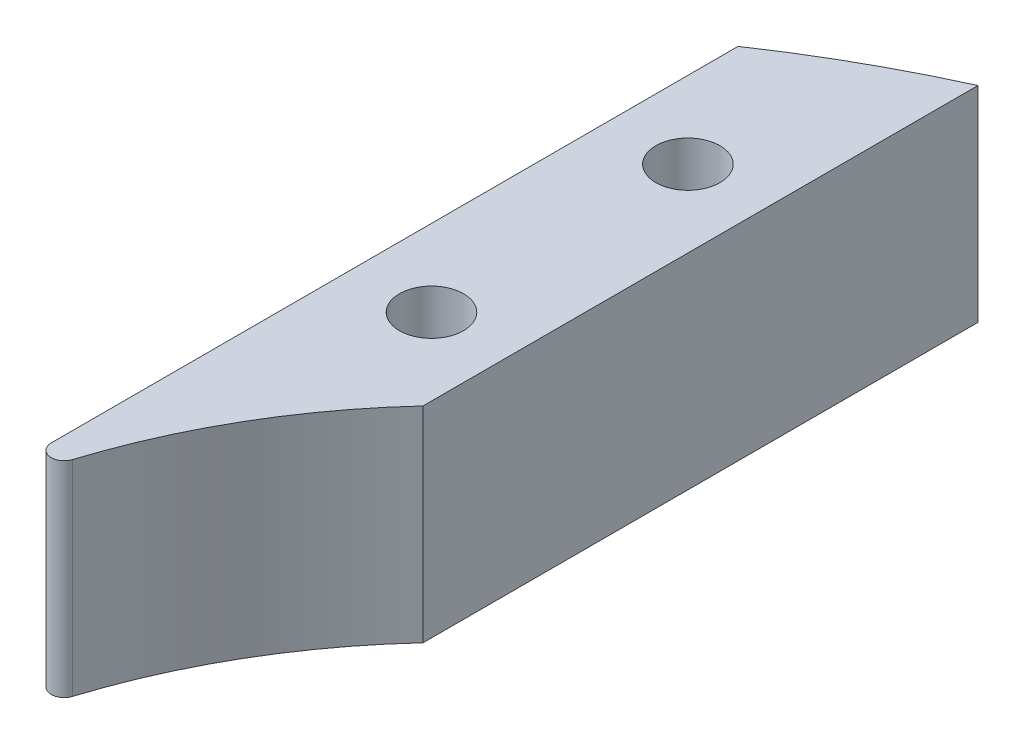
from build123d import *

# Parameters (mm, degrees)
SKETCH_1_R      = 1.25
EXTRUDE_1_DEPTH = 8
FILLET_1_R      = 0.5


with BuildPart() as part:
    # 草图1 → 凸台-拉伸1 (new body)
    with BuildSketch(Plane(origin=(0, 0, 0), x_dir=(1, 0, 0), z_dir=(0, 1, 0))):
        with BuildLine():
            Line((-22.9, 33.888050991), (-22.9, 2.142428529))
            ThreePointArc((-22.9, 2.142428529), (-21.006975687, 9.365200078), (-16.9, 15.600961509))
            Line((-16.9, 15.600961509), (-16.9, 37.24513391))
            ThreePointArc((-16.9, 37.24513391), (-19.970666024, 35.692891429), (-22.9, 33.888050991))
        make_face()
        with Locations((-19.9, 28.931907268)):
            Circle(SKETCH_1_R, mode=Mode.SUBTRACT)
        with Locations((-19.9, 18.931907268)):
            Circle(SKETCH_1_R, mode=Mode.SUBTRACT)
    extrude(amount=EXTRUDE_1_DEPTH)

    # 圆角1
    fillet_1_edges = [part.edges().sort_by_distance(p)[0] for p in [
        (-22.9, 4, -2.142428529),
    ]]
    fillet(fillet_1_edges, radius=FILLET_1_R)


solid = part.part
